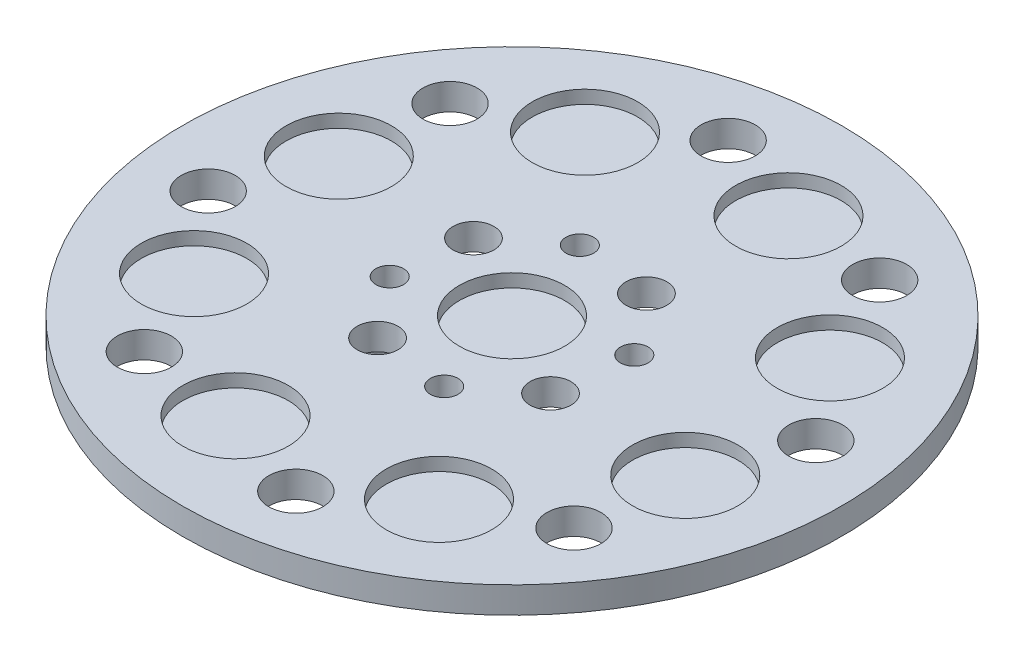
from build123d import *

# Parameters (mm, degrees)
SKETCH1_R           = 25
BOSS_EXTRUDE1_DEPTH = 2
SKETCH2_R           = 1.05
CUT_EXTRUDE1_DEPTH  = 3
SKETCH3_R           = 4
CUT_EXTRUDE2_DEPTH  = 1
SKETCH4_R           = 3
SKETCH4_R_2         = 1.95
BOSS_EXTRUDE2_DEPTH = 6
FILLET1_R           = 1
SKETCH5_R           = 2.05
CUT_EXTRUDE3_DEPTH  = 9
SKETCH7_R           = 1.55
CUT_EXTRUDE4_DEPTH  = 9


with BuildPart() as part:
    # Sketch1 → Boss-Extrude1 (new body)
    with BuildSketch(Plane(origin=(0, 0, 0), x_dir=(1, 0, 0), z_dir=(0, 1, 0))):
        Circle(SKETCH1_R)
    extrude(amount=BOSS_EXTRUDE1_DEPTH)

    # Sketch2 → Cut-Extrude1 (cut, through all)
    with BuildSketch(Plane(origin=(0, 2, 0), x_dir=(1, 0, 0), z_dir=(0, 1, 0))):
        with Locations((-2.066368974, 7.209723938)):
            Circle(SKETCH2_R)
        with Locations((7.209723938, 2.066368974)):
            Circle(SKETCH2_R)
        with Locations((2.066368974, -7.209723938)):
            Circle(SKETCH2_R)
        with Locations((-7.209723938, -2.066368974)):
            Circle(SKETCH2_R)
    extrude(amount=-CUT_EXTRUDE1_DEPTH, mode=Mode.SUBTRACT)

    # Sketch3 → Cut-Extrude2 (cut)
    with BuildSketch(Plane(origin=(0, 2, 0), x_dir=(1, 0, 0), z_dir=(0, 1, 0))):
        Circle(SKETCH3_R)
        with Locations((17.056217149, -3.916051143)):
            Circle(SKETCH3_R)
        with Locations((9.291500489, -14.829633126)):
            Circle(SKETCH3_R)
        with Locations((-3.916051143, -17.056217149)):
            Circle(SKETCH3_R)
        with Locations((-14.829633126, -9.291500489)):
            Circle(SKETCH3_R)
        with Locations((-17.056217149, 3.916051143)):
            Circle(SKETCH3_R)
        with Locations((-9.291500489, 14.829633126)):
            Circle(SKETCH3_R)
        with Locations((3.916051143, 17.056217149)):
            Circle(SKETCH3_R)
        with Locations((14.829633126, 9.291500489)):
            Circle(SKETCH3_R)
    extrude(amount=-CUT_EXTRUDE2_DEPTH, mode=Mode.SUBTRACT)

    # Sketch4 → Boss-Extrude2 (add)
    with BuildSketch(Plane.XZ):
        with Locations((2.066368974, 7.209723938)):
            Circle(SKETCH4_R)
        with Locations((2.066368974, 7.209723938)):
            Circle(SKETCH4_R_2, mode=Mode.SUBTRACT)
        with Locations((7.209723938, -2.066368974)):
            Circle(SKETCH4_R)
        with Locations((7.209723938, -2.066368974)):
            Circle(SKETCH4_R_2, mode=Mode.SUBTRACT)
        with Locations((-2.066368974, -7.209723938)):
            Circle(SKETCH4_R)
        with Locations((-2.066368974, -7.209723938)):
            Circle(SKETCH4_R_2, mode=Mode.SUBTRACT)
        with Locations((-7.209723938, 2.066368974)):
            Circle(SKETCH4_R)
        with Locations((-7.209723938, 2.066368974)):
            Circle(SKETCH4_R_2, mode=Mode.SUBTRACT)
    extrude(amount=BOSS_EXTRUDE2_DEPTH)

    # Fillet1
    fillet1_edges = [part.edges().sort_by_distance(p)[0] for p in [
        (-0.933631026, 0, 7.209723938),
        (4.209723938, 0, -2.066368974),
        (-5.066368974, 0, -7.209723938),
        (-10.209723938, 0, 2.066368974),
    ]]
    fillet(fillet1_edges, radius=FILLET1_R)

    # Sketch5 → Cut-Extrude3 (cut, through all)
    with BuildSketch(Plane(origin=(0, 2, 0), x_dir=(1, 0, 0), z_dir=(0, 1, 0))):
        with Locations((-11.594389967, -16.296322324)):
            Circle(SKETCH5_R)
        with Locations((-19.721711793, -3.324768254)):
            Circle(SKETCH5_R)
        with Locations((-16.296322324, 11.594389967)):
            Circle(SKETCH5_R)
        with Locations((-3.324768254, 19.721711793)):
            Circle(SKETCH5_R)
        with Locations((11.594389967, 16.296322324)):
            Circle(SKETCH5_R)
        with Locations((19.721711793, 3.324768254)):
            Circle(SKETCH5_R)
        with Locations((16.296322324, -11.594389967)):
            Circle(SKETCH5_R)
        with Locations((3.324768254, -19.721711793)):
            Circle(SKETCH5_R)
    extrude(amount=-CUT_EXTRUDE3_DEPTH, mode=Mode.SUBTRACT)

    # Sketch7 → Cut-Extrude4 (cut, through all)
    with BuildSketch(Plane(origin=(0, 2, -2), x_dir=(1, 0, 0), z_dir=(0, -1, 0))):
        with Locations((-3.636901173, 8.559188201)):
            Circle(SKETCH7_R)
        with Locations((6.559188201, 5.636901173)):
            Circle(SKETCH7_R)
        with Locations((3.636901173, -4.559188201)):
            Circle(SKETCH7_R)
        with Locations((-6.559188201, -1.636901173)):
            Circle(SKETCH7_R)
    extrude(amount=CUT_EXTRUDE4_DEPTH, mode=Mode.SUBTRACT)


solid = part.part
